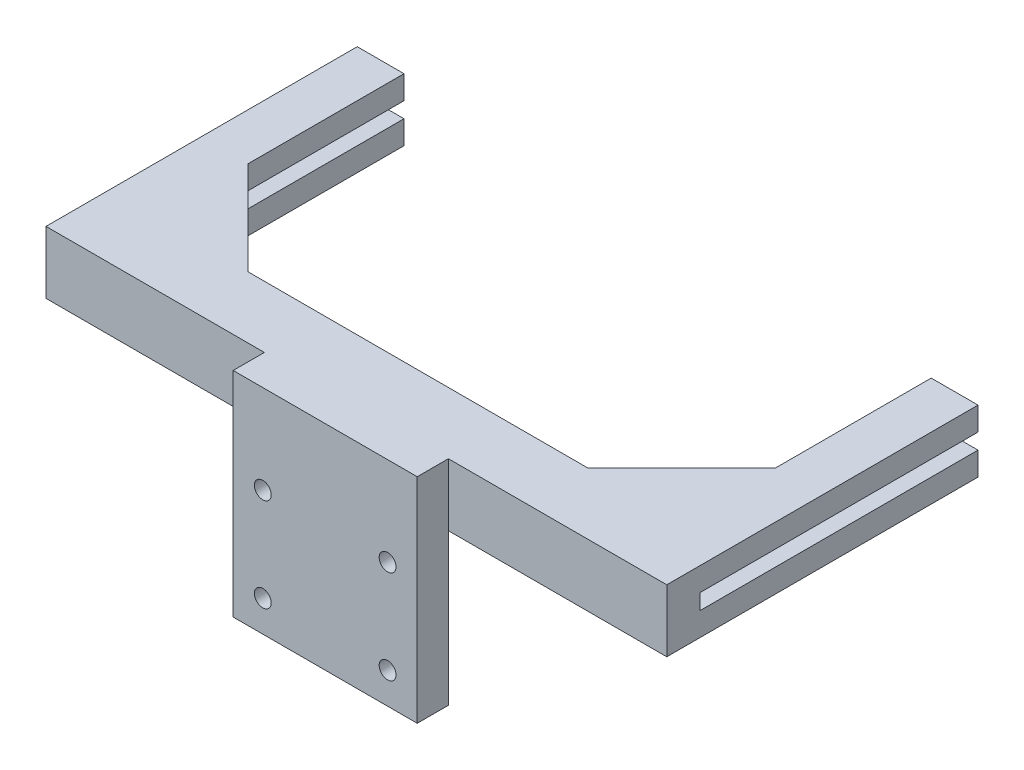
from build123d import *

# Parameters (mm, degrees)
SKETCH1_W                                  = 59
SKETCH1_H                                  = 50
BOSS_EXTRUDE1_DEPTH                        = 10
SKETCH2_R                                  = 2.7
CUT_EXTRUDE1_DEPTH                         = 10
MIRROR1_AT_THE_SECOND_PLANE_COPY_1_SKETC_R = 2.7
MIRROR1_AT_THE_SECOND_PLANE_COPY_1_DEPTH   = 10
SKETCH9_W                                  = 59
SKETCH9_H                                  = 10
BOSS_EXTRUDE10_DEPTH                       = 18.461375068
SKETCH12_W                                 = 59
SKETCH12_H                                 = 20
BOSS_EXTRUDE11_DEPTH                       = 19.770139482
SKETCH13_W                                 = 19.770139482
SKETCH13_H                                 = 20
BOSS_EXTRUDE12_DEPTH                       = 70
SKETCH14_W                                 = 15
SKETCH14_H                                 = 20
BOSS_EXTRUDE13_DEPTH                       = 80
BOSS_EXTRUDE14_DEPTH                       = 20
BOSS_EXTRUDE15_DEPTH                       = 5
SKETCH16_W                                 = 199
SKETCH16_H                                 = 5
CUT_EXTRUDE3_DEPTH                         = 109.350147663


with BuildPart() as part:
    # Sketch1 → Boss-Extrude1 (new body)
    with BuildSketch(Plane.XY):
        Rectangle(SKETCH1_W, SKETCH1_H)
    extrude(amount=BOSS_EXTRUDE1_DEPTH)

    # Sketch2 → Cut-Extrude1 (cut)
    with BuildSketch(Plane.XY.offset(10)):
        with Locations((-20, 15)):
            Circle(SKETCH2_R)
    cut_extrude1 = extrude(amount=-CUT_EXTRUDE1_DEPTH, mode=Mode.SUBTRACT)

    # Mirror1: Cut-Extrude1 across plane
    add(cut_extrude1.mirror(Plane.ZX), mode=Mode.SUBTRACT)

    # Mirror1 at the second plane: Cut-Extrude1 across plane
    add(cut_extrude1.mirror(Plane(origin=(0, 0, 0), x_dir=(0, 0, 1), z_dir=(1, 0, 0))), mode=Mode.SUBTRACT)

    # Mirror1 at the second plane copy 1 sketc → Mirror1 at the second plane copy 1 (cut)
    with BuildSketch(Plane(origin=(0, 0, 10), x_dir=(-1, 0, 0), z_dir=(0, 0, 1))):
        with Locations((-20, 15)):
            Circle(MIRROR1_AT_THE_SECOND_PLANE_COPY_1_SKETC_R)
    extrude(amount=-MIRROR1_AT_THE_SECOND_PLANE_COPY_1_DEPTH, mode=Mode.SUBTRACT)

    # Sketch9 → Boss-Extrude10 (add)
    with BuildSketch(Plane(origin=(0, 25, 0), x_dir=(1, 0, 0), z_dir=(0, 1, 0))):
        with Locations((0, -5)):
            Rectangle(SKETCH9_W, SKETCH9_H)
    extrude(amount=BOSS_EXTRUDE10_DEPTH)

    # Sketch12 → Boss-Extrude11 (add)
    with BuildSketch(Plane(origin=(0, 0, 0), x_dir=(-1, 0, 0), z_dir=(0, 0, -1))):
        with Locations((0, 33.461375068)):
            Rectangle(SKETCH12_W, SKETCH12_H)
    extrude(amount=BOSS_EXTRUDE11_DEPTH)

    # Sketch13 → Boss-Extrude12 (add)
    with BuildSketch(Plane.ZY.offset(29.5)):
        with Locations((-9.885069741, 33.461375068)):
            Rectangle(SKETCH13_W, SKETCH13_H)
    boss_extrude12 = extrude(amount=BOSS_EXTRUDE12_DEPTH)

    # Sketch14 → Boss-Extrude13 (add)
    with BuildSketch(Plane(origin=(0, 0, -19.770139482), x_dir=(-1, 0, 0), z_dir=(0, 0, -1))):
        with Locations((92, 33.461375068)):
            Rectangle(SKETCH14_W, SKETCH14_H)
    boss_extrude13 = extrude(amount=BOSS_EXTRUDE13_DEPTH)

    # Mirror2: Boss-Extrude12, Boss-Extrude13 across plane
    add(boss_extrude12.mirror(Plane(origin=(0, 0, 0), x_dir=(0, 0, 1), z_dir=(1, 0, 0))))
    add(boss_extrude13.mirror(Plane(origin=(0, 0, 0), x_dir=(0, 0, 1), z_dir=(1, 0, 0))))

    # Sketch15 → Boss-Extrude14 (add)
    with BuildSketch(Plane(origin=(0, 43.461375068, 0), x_dir=(1, 0, 0), z_dir=(0, 1, 0))):
        Polygon((-84.5, 19.770139482), (-54.5, 19.770139482), (-84.5, 49.770139482), align=None)
    boss_extrude14 = extrude(amount=-BOSS_EXTRUDE14_DEPTH)

    # Mirror3: Boss-Extrude14 across plane
    add(boss_extrude14.mirror(Plane(origin=(0, 0, 0), x_dir=(0, 0, 1), z_dir=(1, 0, 0))))

    # Sketch19 → Boss-Extrude15 (add)
    with BuildSketch(Plane(origin=(10, 0, 0), x_dir=(0, 0, -1), z_dir=(1, 0, 0))):
        Polygon((0, -25), (19.770139482, 23.461375068), (0, 23.461375068), align=None)
    boss_extrude15 = extrude(amount=-BOSS_EXTRUDE15_DEPTH)

    # Mirror4: Boss-Extrude15 across plane
    add(boss_extrude15.mirror(Plane(origin=(0, 0, 0), x_dir=(0, 0, 1), z_dir=(1, 0, 0))))

    # Sketch16 → Cut-Extrude3 (cut)
    with BuildSketch(Plane.XY.offset(-120)):
        with Locations((0, 33.461375068)):
            Rectangle(SKETCH16_W, SKETCH16_H)
    extrude(amount=CUT_EXTRUDE3_DEPTH, mode=Mode.SUBTRACT)


solid = part.part
